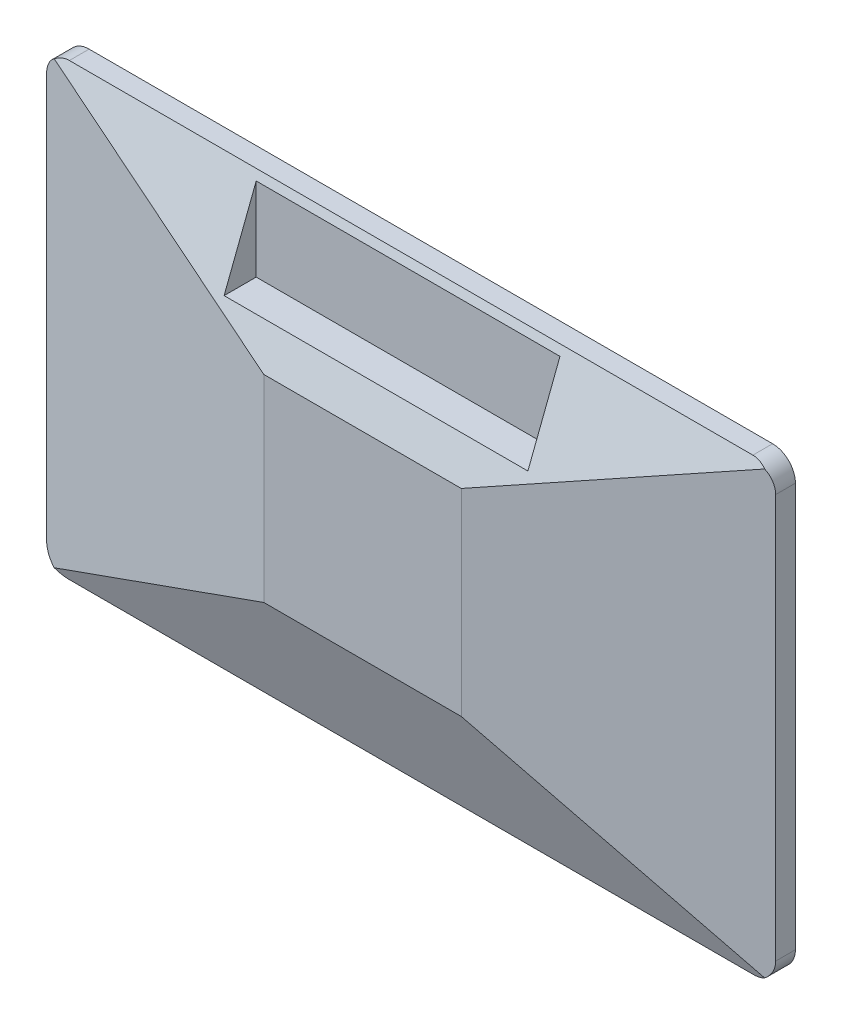
from build123d import *

# Parameters (mm, degrees)
ESQUISSE1_W             = 480
ESQUISSE1_H             = 296
BOSS_EXTRU_1_DEPTH      = 13
ESQUISSE2_W             = 130
ESQUISSE2_H             = 130
ESQUISSE3_W             = 460
ESQUISSE3_H             = 276
ENL_V_MAT_EXTRU_1_DEPTH = 2
CONG_1_R                = 15
ESQUISSE4_W             = 200
ESQUISSE4_H             = 53.029675638
ENL_V_MAT_EXTRU_2_DEPTH = 61.0000001
ESQUISSE5_W             = 15
ESQUISSE5_H             = 5
BOSS_EXTRU_2_DEPTH      = 1


with BuildPart() as part:
    # Esquisse1 → Boss.-Extru.1 (new body)
    with BuildSketch(Plane.XY):
        Rectangle(ESQUISSE1_W, ESQUISSE1_H)
    extrude(amount=BOSS_EXTRU_1_DEPTH)

    # Esquisse2 → section 0 of lissage1
    with BuildSketch(Plane.XY.offset(45), mode=Mode.PRIVATE) as lissage1_s0:
        Rectangle(ESQUISSE2_W, ESQUISSE2_H)
    # loft up to a face of the part (lissage1)
    loft([lissage1_s0.sketch, part.faces().sort_by_distance((0, 0, 13))[0]])

    # Esquisse3 → Enlèv. mat.-Extru.1 (cut)
    with BuildSketch(Plane(origin=(0, 0, 0), x_dir=(-1, 0, 0), z_dir=(0, 0, -1))):
        Rectangle(ESQUISSE3_W, ESQUISSE3_H)
    extrude(amount=-ENL_V_MAT_EXTRU_1_DEPTH, mode=Mode.SUBTRACT)

    # Congé1
    cong_1_edges = [part.edges().sort_by_distance(p)[0] for p in [
        (-240, 148, 6.5),
        (240, 148, 6.5),
        (240, -148, 6.5),
        (-240, -148, 6.5),
    ]]
    fillet(cong_1_edges, radius=CONG_1_R)

    # Esquisse4 → Enlèv. mat.-Extru.2 (cut, through all)
    with BuildSketch(Plane(origin=(0, 88, 0), x_dir=(1, 0, 0), z_dir=(0, 1, 0))):
        with Locations((0, -41.514837819)):
            Rectangle(ESQUISSE4_W, ESQUISSE4_H)
    extrude(amount=ENL_V_MAT_EXTRU_2_DEPTH, mode=Mode.SUBTRACT)

    # Esquisse5 → Boss.-Extru.2 (add)
    with BuildSketch(Plane(origin=(0, 0, 0), x_dir=(-1, 0, 0), z_dir=(0, 0, -1))):
        with Locations((-208.124292846, 143.5)):
            Rectangle(ESQUISSE5_W, ESQUISSE5_H)
        with Locations((-185.124292846, 143.5)):
            Rectangle(ESQUISSE5_W, ESQUISSE5_H)
        with Locations((-162.124292846, 143.5)):
            Rectangle(ESQUISSE5_W, ESQUISSE5_H)
    extrude(amount=BOSS_EXTRU_2_DEPTH)


solid = part.part
